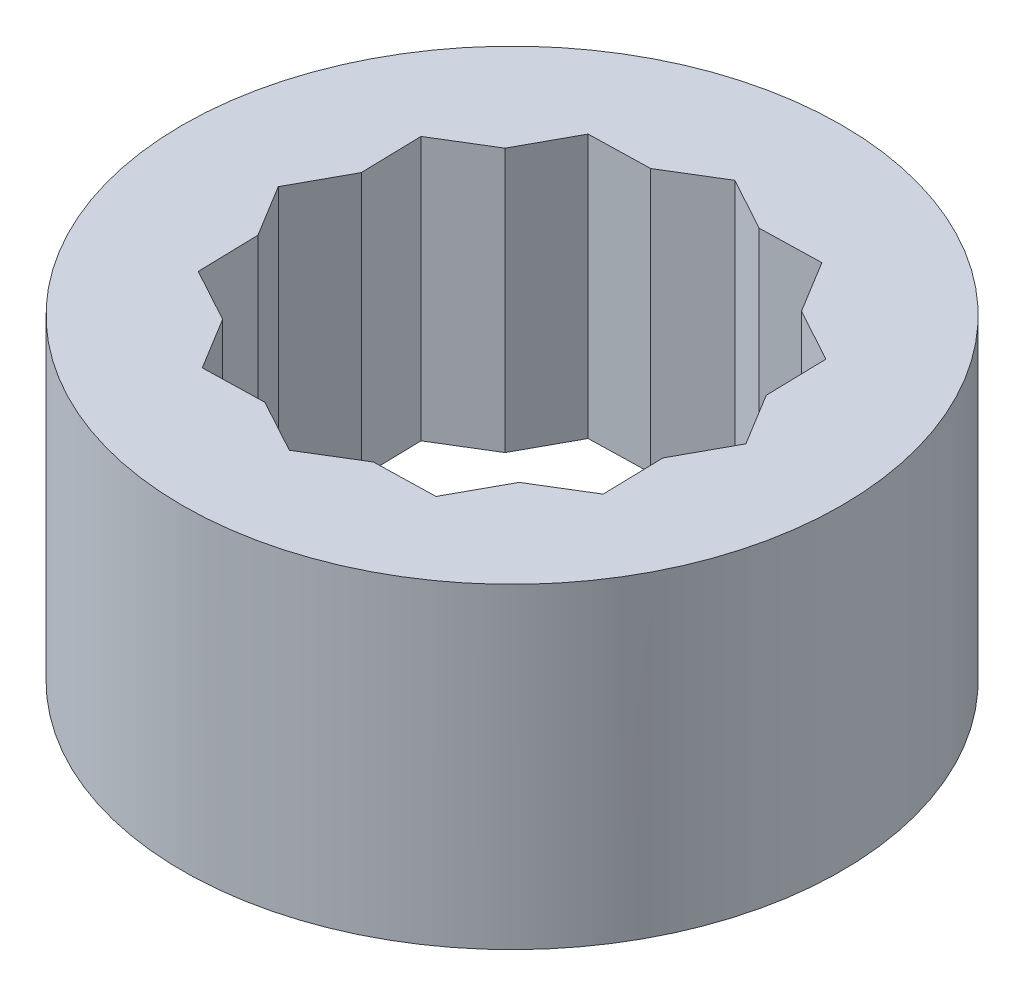
from build123d import *

# Parameters (mm, degrees)
SKETCH1_R           = 15.875
BOSS_EXTRUDE1_DEPTH = 12.7
CUT_EXTRUDE1_DEPTH  = 13.7
SKETCH3_R           = 15.875
BOSS_EXTRUDE2_DEPTH = 2.54
SKETCH4_R           = 15.08125
CUT_EXTRUDE2_DEPTH  = 2.54


with BuildPart() as part:
    # Sketch1 → Boss-Extrude1 (new body)
    with BuildSketch(Plane(origin=(0, 0, 0), x_dir=(1, 0, 0), z_dir=(0, 1, 0))):
        Circle(SKETCH1_R)
    extrude(amount=BOSS_EXTRUDE1_DEPTH)

    # Sketch2 → Cut-Extrude1 (cut, through all)
    with BuildSketch(Plane(origin=(0, 12.7, 0), x_dir=(1, 0, 0), z_dir=(0, 1, 0))):
        Polygon((-9.38920922, -5.728023239), (0.266009029, -10.995305325), (9.655218248, -5.267282086), (9.38920922, 5.728023239), (-0.266009029, 10.995305325), (-9.655218248, 5.267282086), align=None)
        Polygon((-5.267282086, -9.655218248), (5.728023239, -9.38920922), (10.995305325, 0.266009029), (5.267282086, 9.655218248), (-5.728023239, 9.38920922), (-10.995305325, -0.266009029), align=None)
        Polygon((-7.13938722, 6.802101287), (-2.781840057, 9.460486124), (-5.728023239, 9.38920922), align=None)
        Polygon((-9.583941344, 2.321098904), (-7.13938722, 6.802101287), (-9.655218248, 5.267282086), align=None)
        Polygon((-10.995305325, -0.266009029), (-9.460486124, -2.781840057), (-9.583941344, 2.321098904), align=None)
        Polygon((-9.38920922, -5.728023239), (-6.802101287, -7.13938722), (-9.460486124, -2.781840057), align=None)
        Polygon((-5.267282086, -9.655218248), (-2.321098904, -9.583941344), (-6.802101287, -7.13938722), align=None)
        Polygon((0.266009029, -10.995305325), (2.781840057, -9.460486124), (-2.321098904, -9.583941344), align=None)
        Polygon((5.728023239, -9.38920922), (7.13938722, -6.802101287), (2.781840057, -9.460486124), align=None)
        Polygon((7.13938722, -6.802101287), (9.655218248, -5.267282086), (9.583941344, -2.321098904), align=None)
        Polygon((9.460486124, 2.781840057), (9.583941344, -2.321098904), (10.995305325, 0.266009029), align=None)
        Polygon((6.802101287, 7.13938722), (9.460486124, 2.781840057), (9.38920922, 5.728023239), align=None)
        Polygon((2.321098904, 9.583941344), (6.802101287, 7.13938722), (5.267282086, 9.655218248), align=None)
        Polygon((-2.781840057, 9.460486124), (2.321098904, 9.583941344), (-0.266009029, 10.995305325), align=None)
    extrude(amount=-CUT_EXTRUDE1_DEPTH, mode=Mode.SUBTRACT)

    # Sketch3 → Boss-Extrude2 (add)
    with BuildSketch(Plane.XZ):
        Circle(SKETCH3_R)
    extrude(amount=BOSS_EXTRUDE2_DEPTH)

    # Sketch4 → Cut-Extrude2 (cut)
    with BuildSketch(Plane.XZ.offset(2.54)):
        Circle(SKETCH4_R)
    extrude(amount=-CUT_EXTRUDE2_DEPTH, mode=Mode.SUBTRACT)


solid = part.part
